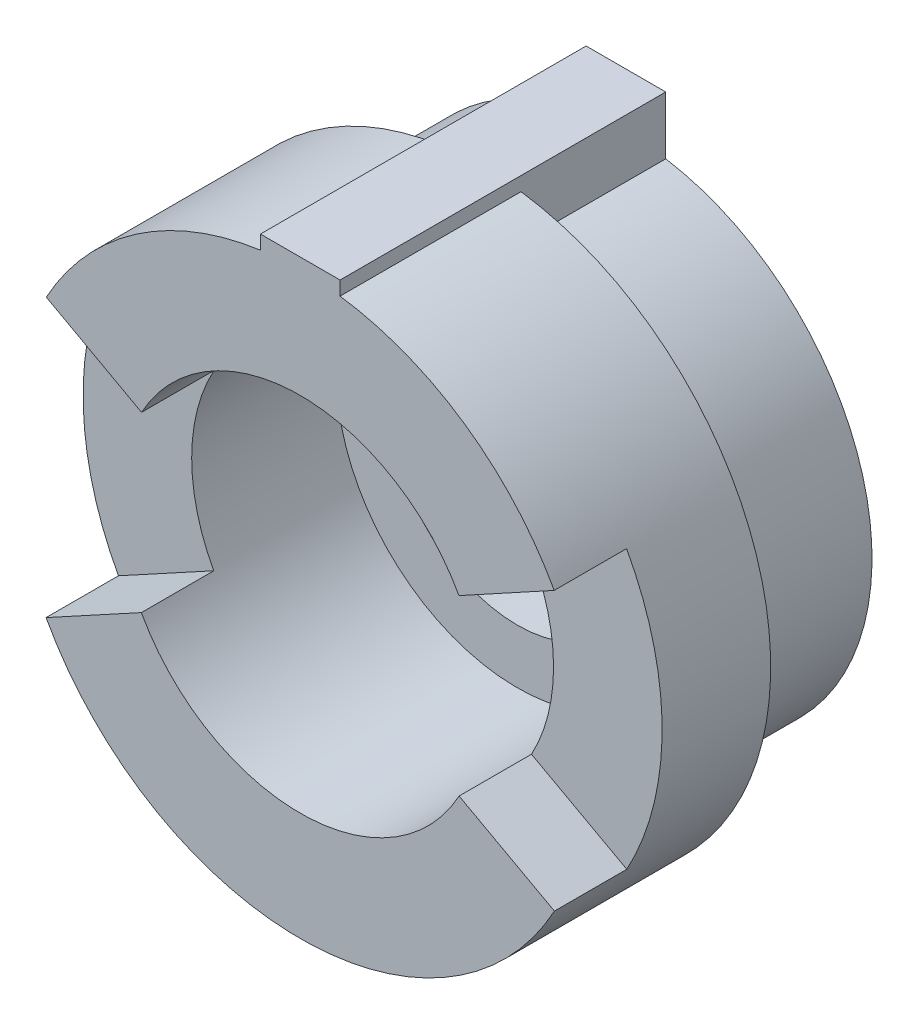
from build123d import *

# Parameters (mm, degrees)
SKETCH1_R                = 8
SKETCH1_R_2              = 3.5
BOSS_EXTRUDE1_DEPTH      = 3
SKETCH2_R                = 8
SKETCH2_R_2              = 5
BOSS_EXTRUDE2_DEPTH      = 6
WRAP3_SECTION_W          = 4
WRAP3_SECTION_H          = 2
WRAP3_ANGLE              = 57.295779513
WRAP3_SECTOR_2_SECTION_W = 4
WRAP3_SECTOR_2_SECTION_H = 2
WRAP3_SECTOR_2_ANGLE     = 57.295779513
CUT_EXTRUDE1_DEPTH       = 4
BOSS_EXTRUDE3_DEPTH      = 9


with BuildPart() as part:
    # Sketch1 → Boss-Extrude1 (new body)
    with BuildSketch(Plane.XY):
        Circle(SKETCH1_R)
        Circle(SKETCH1_R_2, mode=Mode.SUBTRACT)
    extrude(amount=BOSS_EXTRUDE1_DEPTH)

    # Sketch2 → Boss-Extrude2 (add)
    with BuildSketch(Plane.XY.offset(3)):
        Circle(SKETCH2_R)
        Circle(SKETCH2_R_2, mode=Mode.SUBTRACT)
    extrude(amount=BOSS_EXTRUDE2_DEPTH)

    # Wrap3 section (on wrap section) → Wrap3 (revolve, cut)
    with BuildSketch(Plane(origin=(0, 0, 0), x_dir=(-0.8779640629990781, -0.4787265441587198, 0), z_dir=(0.4787265441587198, -0.8779640629990781, 0))):
        with Locations((6, -8)):
            Rectangle(WRAP3_SECTION_W, WRAP3_SECTION_H)
    revolve(axis=Axis((0, 0, 0), (0, 0, -1)), revolution_arc=WRAP3_ANGLE, mode=Mode.SUBTRACT)

    # Wrap3 sector 2 section (on wrap section) → Wrap3 sector 2 (revolve, cut)
    with BuildSketch(Plane(origin=(0, 0, 0), x_dir=(0.8772005042746819, 0.4801242290285337, 0), z_dir=(-0.4801242290285337, 0.8772005042746819, 0))):
        with Locations((6, -8)):
            Rectangle(WRAP3_SECTOR_2_SECTION_W, WRAP3_SECTOR_2_SECTION_H)
    revolve(axis=Axis((0, 0, 0), (0, 0, -1)), revolution_arc=WRAP3_SECTOR_2_ANGLE, mode=Mode.SUBTRACT)

    # Sketch5 → Cut-Extrude1 (cut)
    with BuildSketch(Plane(origin=(0, 0, 0), x_dir=(-1, 0, 0), z_dir=(0, 0, -1))):
        with BuildLine():
            Line((-1.1, 6.710439628), (-1.1, 7.924014134))
            ThreePointArc((-1.1, 7.924014134), (0, -8), (1.1, 7.924014134))
            Line((1.1, 7.924014134), (1.1, 6.710439628))
            ThreePointArc((1.1, 6.710439628), (0, -6.8), (-1.1, 6.710439628))
        make_face()
    extrude(amount=-CUT_EXTRUDE1_DEPTH, mode=Mode.SUBTRACT)

    # Sketch6 → Boss-Extrude3 (add)
    with BuildSketch(Plane(origin=(0, 0, 0), x_dir=(-1, 0, 0), z_dir=(0, 0, -1))):
        with BuildLine():
            Line((-1.1, 7.731159285), (-1.1, 8.310439628))
            Line((-1.1, 8.310439628), (1.1, 8.310439628))
            Line((1.1, 8.310439628), (1.1, 7.731159285))
            ThreePointArc((1.1, 7.731159285), (0, 7.807145151), (-1.1, 7.731159285))
        make_face()
    extrude(amount=-BOSS_EXTRUDE3_DEPTH)


solid = part.part
